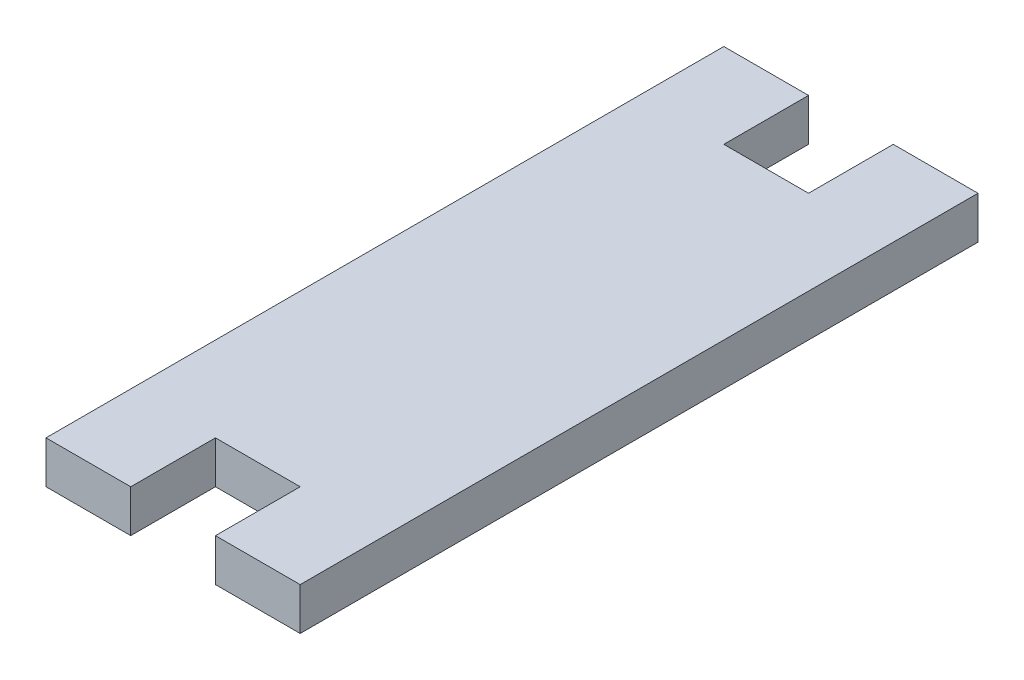
from build123d import *

# Parameters (mm, degrees)
SCHIZZO1_W                   = 30
SCHIZZO1_H                   = 80
ESTRUSIONE_ESTRUSIONE1_DEPTH = 5
SCHIZZO2_W                   = 10
SCHIZZO2_H                   = 10
TAGLIO_ESTRUSIONE1_DEPTH     = 6


with BuildPart() as part:
    # Schizzo1 → Estrusione-Estrusione1 (new body)
    with BuildSketch(Plane(origin=(0, 0, 0), x_dir=(1, 0, 0), z_dir=(0, 1, 0))):
        with Locations((-24.969948018, -5.308641975)):
            Rectangle(SCHIZZO1_W, SCHIZZO1_H)
    extrude(amount=ESTRUSIONE_ESTRUSIONE1_DEPTH)

    # Schizzo2 → Taglio-Estrusione1 (cut, through all)
    with BuildSketch(Plane(origin=(0, 0, 0), x_dir=(1, 0, 0), z_dir=(0, 1, 0))):
        with Locations((-24.969948018, 29.691358025)):
            Rectangle(SCHIZZO2_W, SCHIZZO2_H)
        with Locations((-24.969948018, -40.308641975)):
            Rectangle(SCHIZZO2_W, SCHIZZO2_H)
    extrude(amount=TAGLIO_ESTRUSIONE1_DEPTH, mode=Mode.SUBTRACT)


solid = part.part
